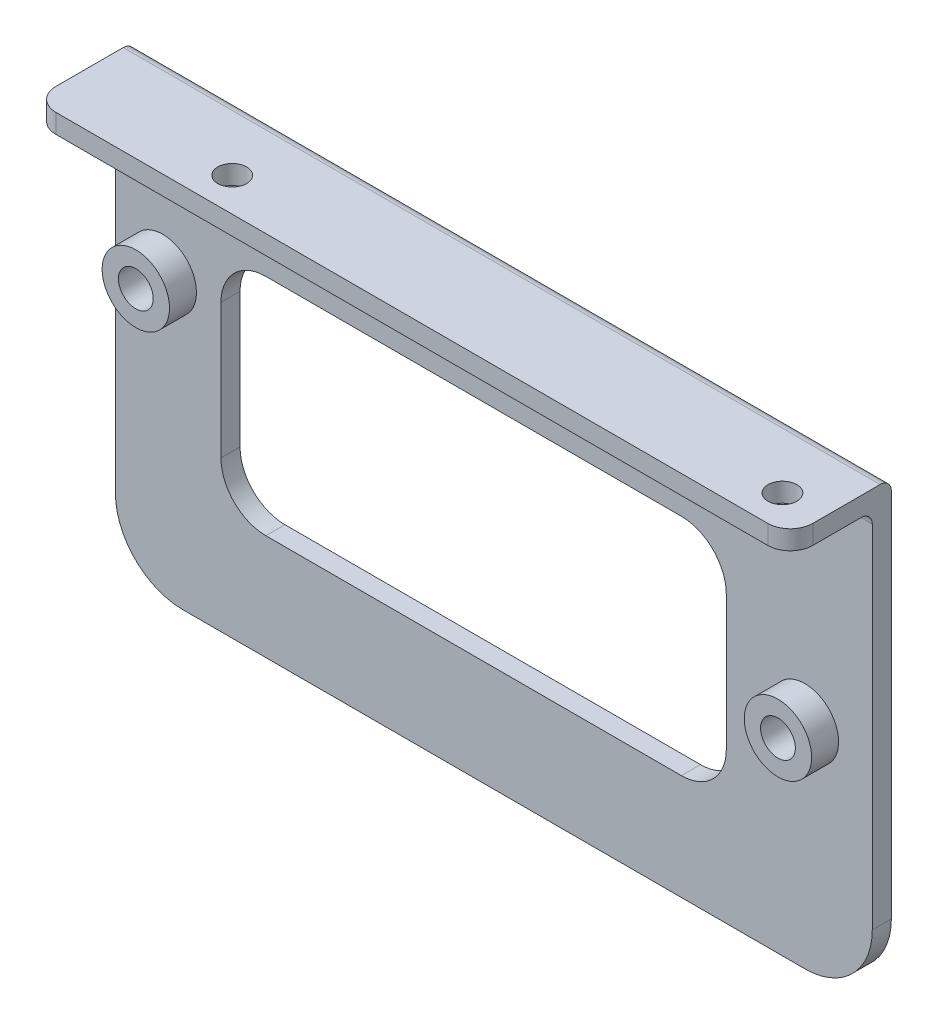
from build123d import *

# Parameters (mm, degrees)
SKETCH1_W             = 85.598
SKETCH1_H             = 50.8
BOSS_EXTRUDE1_DEPTH   = 2.159
SKETCH2_W             = 85.598
SKETCH2_H             = 2.159
BOSS_EXTRUDE2_DEPTH   = 9.271
FILLET1_R             = 1.27
FILLET2_R             = 1.27
FILLET3_R             = 2.54
FILLET4_R             = 7.62
SKETCH3_W             = 57.15
SKETCH3_H             = 25.4
CUT_EXTRUDE1_DEPTH    = 3.159
FILLET5_R             = 5.08
F_4_CLEARANCE_HOLE1_D = 3.2639
SKETCH6_R             = 3.81
BOSS_EXTRUDE3_DEPTH   = 3.048
SKETCH8_R             = 1.9685
CUT_EXTRUDE2_DEPTH    = 3.429
SKETCH9_R             = 0.9525
CUT_EXTRUDE3_DEPTH    = 2.778


with BuildPart() as part:
    # Sketch1 → Boss-Extrude1 (new body)
    with BuildSketch(Plane.XY):
        Rectangle(SKETCH1_W, SKETCH1_H)
    extrude(amount=BOSS_EXTRUDE1_DEPTH)

    # Sketch2 → Boss-Extrude2 (add)
    with BuildSketch(Plane.XY.offset(2.159)):
        with Locations((0, 24.3205)):
            Rectangle(SKETCH2_W, SKETCH2_H)
    extrude(amount=BOSS_EXTRUDE2_DEPTH)

    # Fillet1
    fillet1_edges = [part.edges().sort_by_distance(p)[0] for p in [
        (0, 23.241, 2.159),
    ]]
    fillet(fillet1_edges, radius=FILLET1_R)

    # Fillet2
    fillet2_edges = [part.edges().sort_by_distance(p)[0] for p in [
        (0, 25.4, 0),
    ]]
    fillet(fillet2_edges, radius=FILLET2_R)

    # Fillet3
    fillet3_edges = [part.edges().sort_by_distance(p)[0] for p in [
        (42.799, 24.3205, 11.43),
        (-42.799, 24.3205, 11.43),
    ]]
    fillet(fillet3_edges, radius=FILLET3_R)

    # Fillet4
    fillet4_edges = [part.edges().sort_by_distance(p)[0] for p in [
        (42.799, -25.4, 1.0795),
        (-42.799, -25.4, 1.0795),
    ]]
    fillet(fillet4_edges, radius=FILLET4_R)

    # Sketch3 → Cut-Extrude1 (cut, through all)
    with BuildSketch(Plane.XY.offset(2.159)):
        with Locations((-2.286, -0.762)):
            Rectangle(SKETCH3_W, SKETCH3_H)
    extrude(amount=-CUT_EXTRUDE1_DEPTH, mode=Mode.SUBTRACT)

    # Fillet5
    fillet5_edges = [part.edges().sort_by_distance(p)[0] for p in [
        (-30.861, -13.462, 1.0795),
        (-30.861, 11.938, 1.0795),
        (26.289, 11.938, 1.0795),
        (26.289, -13.462, 1.0795),
    ]]
    fillet(fillet5_edges, radius=FILLET5_R)

    # #4 Clearance Hole1 (through all)
    with Locations(Plane(origin=(0, 23.241, 0), x_dir=(-1, 0, 0), z_dir=(0, -1, 0))):
        with Locations((-38.1, -7.62), (24.13, -7.62)):
            Hole(F_4_CLEARANCE_HOLE1_D / 2)

    # Sketch6 → Boss-Extrude3 (add)
    with BuildSketch(Plane.XY.offset(2.159)):
        with Locations((35.179, -1.27)):
            Circle(SKETCH6_R)
        with Locations((-37.44214, 6.4262)):
            Circle(SKETCH6_R)
    extrude(amount=BOSS_EXTRUDE3_DEPTH)

    # Sketch8 → Cut-Extrude2 (cut)
    with BuildSketch(Plane.XY.offset(5.207)):
        with Locations((-37.44214, 6.4262)):
            Circle(SKETCH8_R)
        with Locations((35.179, -1.27)):
            Circle(SKETCH8_R)
    extrude(amount=-CUT_EXTRUDE2_DEPTH, mode=Mode.SUBTRACT)

    # Sketch9 → Cut-Extrude3 (cut, through all)
    with BuildSketch(Plane.XY.offset(1.778)):
        with Locations((-37.44214, 6.4262)):
            Circle(SKETCH9_R)
        with Locations((35.179, -1.27)):
            Circle(SKETCH9_R)
    extrude(amount=-CUT_EXTRUDE3_DEPTH, mode=Mode.SUBTRACT)


solid = part.part
